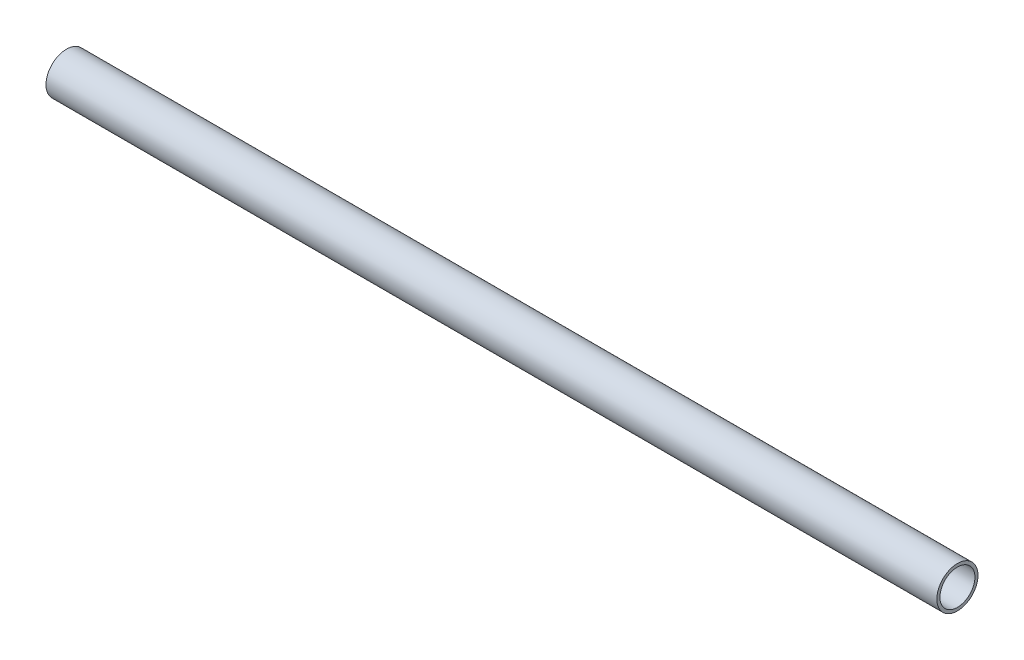
from build123d import *

# Parameters (mm, degrees)
SKETCH2_R           = 12.7
SKETCH2_R_2         = 10.795
BOSS_EXTRUDE1_DEPTH = 550


with BuildPart() as part:
    # Sketch2 → Boss-Extrude1 (new body)
    with BuildSketch(Plane(origin=(0, 0, 0), x_dir=(0, 0, -1), z_dir=(1, 0, 0))):
        with Locations((-5.167827336, 154.488190616)):
            Circle(SKETCH2_R)
        with Locations((-5.167827336, 154.488190616)):
            Circle(SKETCH2_R_2, mode=Mode.SUBTRACT)
    extrude(amount=BOSS_EXTRUDE1_DEPTH)


solid = part.part
